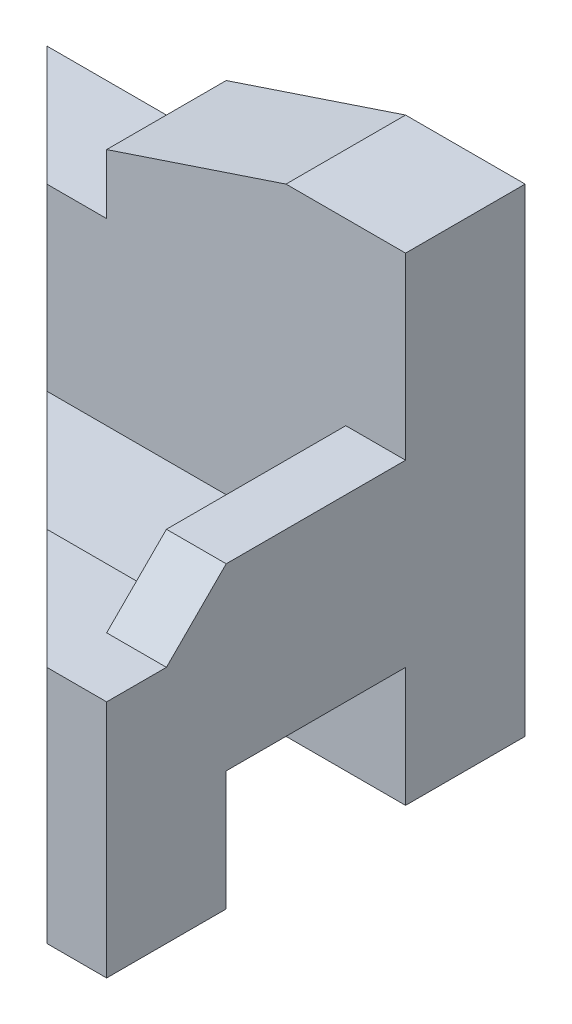
from build123d import *

# Parameters (mm, degrees)
SKETCH1_W           = 40
SKETCH1_H           = 40
BOSS_EXTRUDE1_DEPTH = 10
CUT_EXTRUDE1_DEPTH  = 11
CUT_EXTRUDE2_DEPTH  = 11
SKETCH4_W           = 40
SKETCH4_H           = 20
BOSS_EXTRUDE2_DEPTH = 25
SKETCH5_W           = 15
SKETCH5_H           = 5
CUT_EXTRUDE3_DEPTH  = 41
SKETCH7_W           = 15
SKETCH7_H           = 10
CUT_EXTRUDE4_DEPTH  = 41
CUT_EXTRUDE5_DEPTH  = 31
SKETCH9_W           = 5
SKETCH9_H           = 10
BOSS_EXTRUDE3_DEPTH = 20
CUT_EXTRUDE6_DEPTH  = 6


with BuildPart() as part:
    # Sketch1 → Boss-Extrude1 (new body)
    with BuildSketch(Plane.XY):
        Rectangle(SKETCH1_W, SKETCH1_H)
    extrude(amount=BOSS_EXTRUDE1_DEPTH)

    # Sketch2 → Cut-Extrude1 (cut, through all)
    with BuildSketch(Plane.XY.offset(10)):
        Polygon((10, 20), (-5, 15), (-5, 20), align=None)
    extrude(amount=-CUT_EXTRUDE1_DEPTH, mode=Mode.SUBTRACT)

    # Sketch3 → Cut-Extrude2 (cut, through all)
    with BuildSketch(Plane.XY.offset(10)):
        Polygon((-5, 15), (-5, 10), (-20, 10), (-20, 20), (-5, 20), align=None)
    extrude(amount=-CUT_EXTRUDE2_DEPTH, mode=Mode.SUBTRACT)

    # Sketch4 → Boss-Extrude2 (add)
    with BuildSketch(Plane.XY.offset(10)):
        with Locations((0, -10)):
            Rectangle(SKETCH4_W, SKETCH4_H)
    extrude(amount=BOSS_EXTRUDE2_DEPTH)

    # Sketch5 → Cut-Extrude3 (cut, through all)
    with BuildSketch(Plane.ZY.offset(20)):
        with Locations((17.5, -2.5)):
            Rectangle(SKETCH5_W, SKETCH5_H)
    extrude(amount=-CUT_EXTRUDE3_DEPTH, mode=Mode.SUBTRACT)

    # Sketch7 → Cut-Extrude4 (cut, through all)
    with BuildSketch(Plane.ZY.offset(20)):
        with Locations((17.5, -15)):
            Rectangle(SKETCH7_W, SKETCH7_H)
    extrude(amount=-CUT_EXTRUDE4_DEPTH, mode=Mode.SUBTRACT)

    # Sketch8 → Cut-Extrude5 (cut, through all)
    with BuildSketch(Plane(origin=(0, 10, 0), x_dir=(1, 0, 0), z_dir=(0, 1, 0))):
        Polygon((-20, 0), (15, -35), (-20, -35), align=None)
    extrude(amount=-CUT_EXTRUDE5_DEPTH, mode=Mode.SUBTRACT)

    # Sketch9 → Boss-Extrude3 (add)
    with BuildSketch(Plane.XY.offset(10)):
        with Locations((17.5, 0)):
            Rectangle(SKETCH9_W, SKETCH9_H)
    extrude(amount=BOSS_EXTRUDE3_DEPTH)

    # Sketch10 → Cut-Extrude6 (cut, through all)
    with BuildSketch(Plane.ZY.offset(-15)):
        Polygon((30, 0), (25, 5), (30, 5), align=None)
    extrude(amount=-CUT_EXTRUDE6_DEPTH, mode=Mode.SUBTRACT)


solid = part.part
